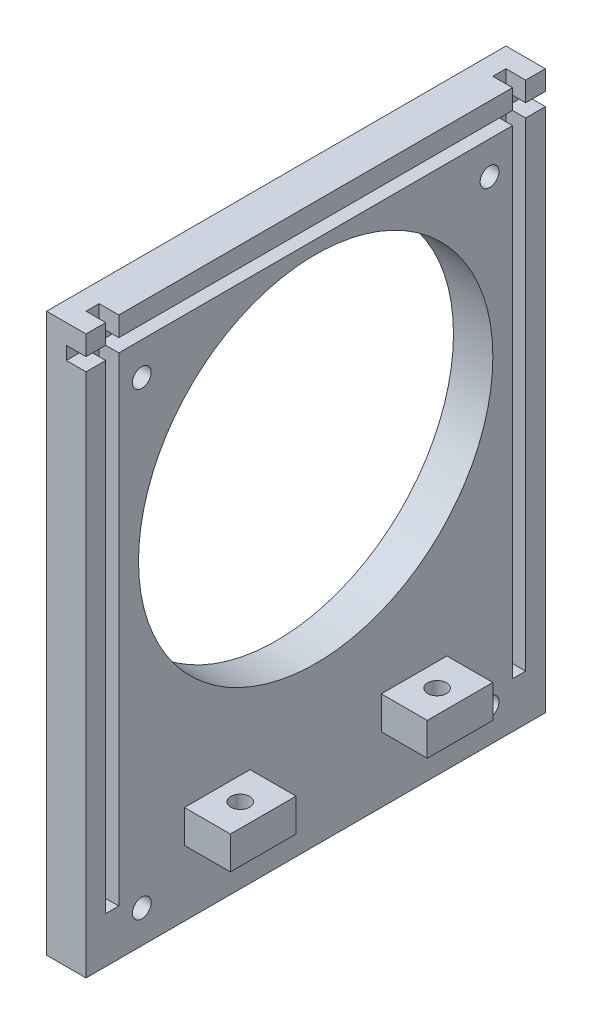
from build123d import *

# Parameters (mm, degrees)
CROQUIS1_W              = 6
CROQUIS1_H              = 70
SALIENTE_EXTRUIR1_DEPTH = 10
CROQUIS2_W              = 6
CROQUIS2_H              = 70
SALIENTE_EXTRUIR2_DEPTH = 75
CROQUIS3_W              = 2
CROQUIS3_H              = 78
CORTAR_EXTRUIR1_DEPTH   = 3
CROQUIS4_W              = 70
CROQUIS4_H              = 2
CORTAR_EXTRUIR2_DEPTH   = 3
CORTAR_EXTRUIR3_REACH   = 8
CROQUIS5_R              = 27
CROQUIS8_R              = 1.435
CORTAR_EXTRUIR5_DEPTH   = 15
MATRIZL1_COUNT          = 2
MATRIZL1_PITCH          = 70
MATRIZL1_COUNT_DIR2     = 2
MATRIZL1_PITCH_DIR2     = 53
CROQUIS12_W             = 10
CROQUIS12_H             = 5
SALIENTE_EXTRUIR3_DEPTH = 7
CROQUIS13_R             = 1.435
CORTAR_EXTRUIR10_DEPTH  = 5


with BuildPart() as part:
    # Croquis1 → Saliente-Extruir1 (new body)
    with BuildSketch(Plane(origin=(0, 0, 0), x_dir=(1, 0, 0), z_dir=(0, 1, 0))):
        Rectangle(CROQUIS1_W, CROQUIS1_H)
    extrude(amount=SALIENTE_EXTRUIR1_DEPTH)

    # Croquis2 → Saliente-Extruir2 (add)
    with BuildSketch(Plane(origin=(0, 10, 0), x_dir=(1, 0, 0), z_dir=(0, 1, 0))):
        Rectangle(CROQUIS2_W, CROQUIS2_H)
    extrude(amount=SALIENTE_EXTRUIR2_DEPTH)

    # Croquis3 → Cortar-Extruir1 (cut)
    with BuildSketch(Plane(origin=(3, 0, 0), x_dir=(0, 0, -1), z_dir=(1, 0, 0))):
        with Locations((-31, 46)):
            Rectangle(CROQUIS3_W, CROQUIS3_H)
    cortar_extruir1 = extrude(amount=-CORTAR_EXTRUIR1_DEPTH, mode=Mode.SUBTRACT)

    # Simetría1: Cortar-Extruir1 across plane
    add(cortar_extruir1.mirror(Plane.XY), mode=Mode.SUBTRACT)

    # Croquis4 → Cortar-Extruir2 (cut)
    with BuildSketch(Plane(origin=(3, 0, 0), x_dir=(0, 0, -1), z_dir=(1, 0, 0))):
        with Locations((0, 81)):
            Rectangle(CROQUIS4_W, CROQUIS4_H)
    extrude(amount=-CORTAR_EXTRUIR2_DEPTH, mode=Mode.SUBTRACT)

    # Croquis5 → Cortar-Extruir3 (cut, up to next)
    with BuildSketch(Plane(origin=(3, 0, 0), x_dir=(0, 0, -1), z_dir=(1, 0, 0)), mode=Mode.PRIVATE) as cortar_extruir3_sk1:
        with Locations((0, 51)):
            Circle(CROQUIS5_R)
    cortar_extruir3_tool1 = extrude(cortar_extruir3_sk1.sketch, amount=-CORTAR_EXTRUIR3_REACH, mode=Mode.PRIVATE) & part.part
    add(cortar_extruir3_tool1.solids().sort_by_distance((3, 51, 0))[0], mode=Mode.SUBTRACT)

    # Croquis8 → Cortar-Extruir5 (cut)
    with BuildSketch(Plane.ZY.offset(3)):
        with Locations((26.5, 75)):
            Circle(CROQUIS8_R)
    cortar_extruir5 = extrude(amount=-CORTAR_EXTRUIR5_DEPTH, mode=Mode.SUBTRACT)

    # MatrizL1: Cortar-Extruir5 2 × 2
    with Locations(*[(0, -i * MATRIZL1_PITCH, -j * MATRIZL1_PITCH_DIR2) for i in range(MATRIZL1_COUNT) for j in range(MATRIZL1_COUNT_DIR2) if (i, j) != (0, 0)]):
        add(cortar_extruir5, mode=Mode.SUBTRACT)

    # Croquis12 → Saliente-Extruir3 (add)
    with BuildSketch(Plane(origin=(3, 0, 0), x_dir=(0, 0, -1), z_dir=(1, 0, 0))):
        with Locations((-15, 12.5)):
            Rectangle(CROQUIS12_W, CROQUIS12_H)
    saliente_extruir3 = extrude(amount=SALIENTE_EXTRUIR3_DEPTH)

    # Simetría4: Saliente-Extruir3 across plane
    add(saliente_extruir3.mirror(Plane.XY))

    # Croquis13 → Cortar-Extruir10 (cut)
    with BuildSketch(Plane(origin=(0, 15, 0), x_dir=(1, 0, 0), z_dir=(0, 1, 0))):
        with Locations((6.5, -15)):
            Circle(CROQUIS13_R)
    cortar_extruir10 = extrude(amount=-CORTAR_EXTRUIR10_DEPTH, mode=Mode.SUBTRACT)

    # Simetría5: Cortar-Extruir10 across plane
    add(cortar_extruir10.mirror(Plane.XY), mode=Mode.SUBTRACT)


solid = part.part
